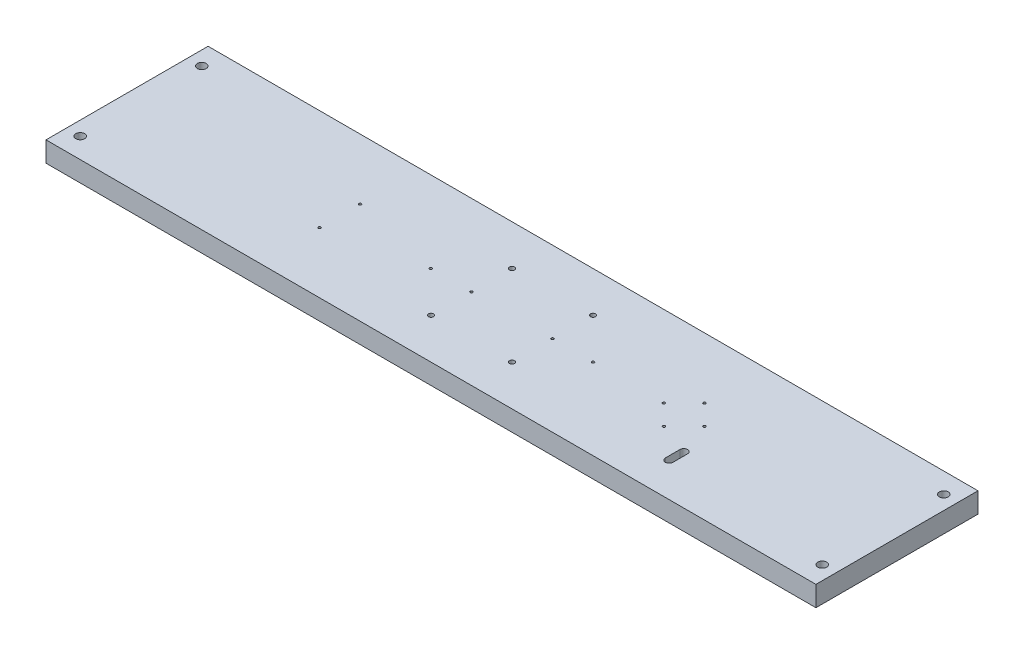
from build123d import *

# Parameters (mm, degrees)
SKETCH1_W           = 482.6
SKETCH1_H           = 101.6
BOSS_EXTRUDE1_DEPTH = 12.7
SKETCH2_R           = 2.7813
CUT_EXTRUDE1_DEPTH  = 13.7
SKETCH3_R           = 1.5875
CUT_EXTRUDE2_DEPTH  = 13.7
SKETCH4_R           = 0.79375
CUT_EXTRUDE3_DEPTH  = 13.7
SKETCH5_R           = 0.79375
CUT_EXTRUDE4_DEPTH  = 13.7
CUT_EXTRUDE5_DEPTH  = 13.7


with BuildPart() as part:
    # Sketch1 → Boss-Extrude1 (new body)
    with BuildSketch(Plane(origin=(0, 0, 0), x_dir=(1, 0, 0), z_dir=(0, 1, 0))):
        Rectangle(SKETCH1_W, SKETCH1_H)
    extrude(amount=BOSS_EXTRUDE1_DEPTH)

    # Sketch2 → Cut-Extrude1 (cut, through all)
    with BuildSketch(Plane(origin=(0, 12.7, 0), x_dir=(1, 0, 0), z_dir=(0, 1, 0))):
        with Locations((-232.5624, 38.1)):
            Circle(SKETCH2_R)
        with Locations((-232.5624, -38.1)):
            Circle(SKETCH2_R)
        with Locations((232.5624, 38.1)):
            Circle(SKETCH2_R)
        with Locations((232.5624, -38.1)):
            Circle(SKETCH2_R)
    extrude(amount=-CUT_EXTRUDE1_DEPTH, mode=Mode.SUBTRACT)

    # Sketch3 → Cut-Extrude2 (cut, through all)
    with BuildSketch(Plane(origin=(0, 12.7, 0), x_dir=(1, 0, 0), z_dir=(0, 1, 0))):
        with Locations((-25.4, 25.4)):
            Circle(SKETCH3_R)
        with Locations((25.4, 25.4)):
            Circle(SKETCH3_R)
        with Locations((25.4, -25.4)):
            Circle(SKETCH3_R)
        with Locations((-25.4, -25.4)):
            Circle(SKETCH3_R)
    extrude(amount=-CUT_EXTRUDE2_DEPTH, mode=Mode.SUBTRACT)

    # Sketch4 → Cut-Extrude3 (cut, through all)
    with BuildSketch(Plane(origin=(0, 12.7, 0), x_dir=(1, 0, 0), z_dir=(0, 1, 0))):
        with Locations((-25.4, 0)):
            Circle(SKETCH4_R)
        with Locations((25.4, 0)):
            Circle(SKETCH4_R)
        with Locations((-50.8, 0)):
            Circle(SKETCH4_R)
        with Locations((50.8, 0)):
            Circle(SKETCH4_R)
        with Locations((-107.95, 12.7)):
            Circle(SKETCH4_R)
        with Locations((-107.95, -12.7)):
            Circle(SKETCH4_R)
        with Locations((107.95, -12.7)):
            Circle(SKETCH4_R)
        with Locations((107.95, 12.7)):
            Circle(SKETCH4_R)
    extrude(amount=-CUT_EXTRUDE3_DEPTH, mode=Mode.SUBTRACT)

    # Sketch5 → Cut-Extrude4 (cut, through all)
    with BuildSketch(Plane(origin=(0, 12.7, 0), x_dir=(1, 0, 0), z_dir=(0, 1, 0))):
        with Locations((95.25, 0)):
            Circle(SKETCH5_R)
        with Locations((120.65, 0)):
            Circle(SKETCH5_R)
    extrude(amount=-CUT_EXTRUDE4_DEPTH, mode=Mode.SUBTRACT)

    # Sketch6 → Cut-Extrude5 (cut, through all)
    with BuildSketch(Plane(origin=(0, 12.7, 0), x_dir=(1, 0, 0), z_dir=(0, 1, 0))):
        with BuildLine():
            Line((125.489928348, -20.1549), (125.489928348, -29.3751))
            ThreePointArc((125.489928348, -29.3751), (127.864828348, -31.75), (130.239728348, -29.3751))
            Line((130.239728348, -29.3751), (130.239728348, -20.1549))
            ThreePointArc((130.239728348, -20.1549), (127.864828348, -17.78), (125.489928348, -20.1549))
        make_face()
    extrude(amount=-CUT_EXTRUDE5_DEPTH, mode=Mode.SUBTRACT)


solid = part.part
